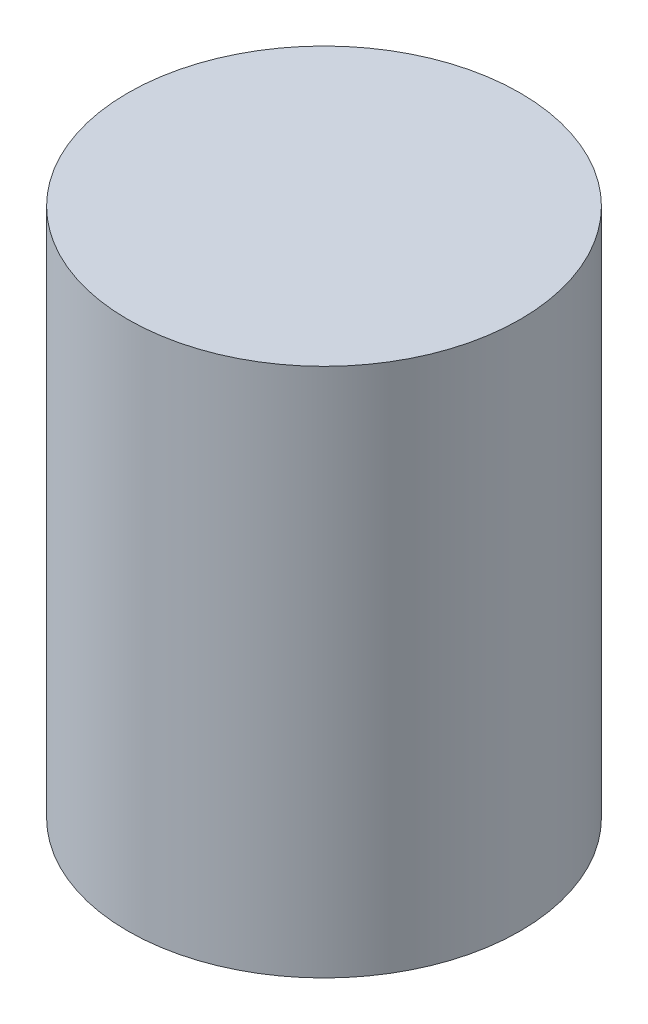
from build123d import *

# Parameters (mm, degrees)
SKETCH_1_R      = 10
EXTRUDE_1_DEPTH = 27


with BuildPart() as part:
    # Эскиз1 → Бобышка-Вытянуть1 (new body)
    with BuildSketch(Plane(origin=(0, 0, 0), x_dir=(1, 0, 0), z_dir=(0, 1, 0))):
        Circle(SKETCH_1_R)
    extrude(amount=EXTRUDE_1_DEPTH)


solid = part.part
